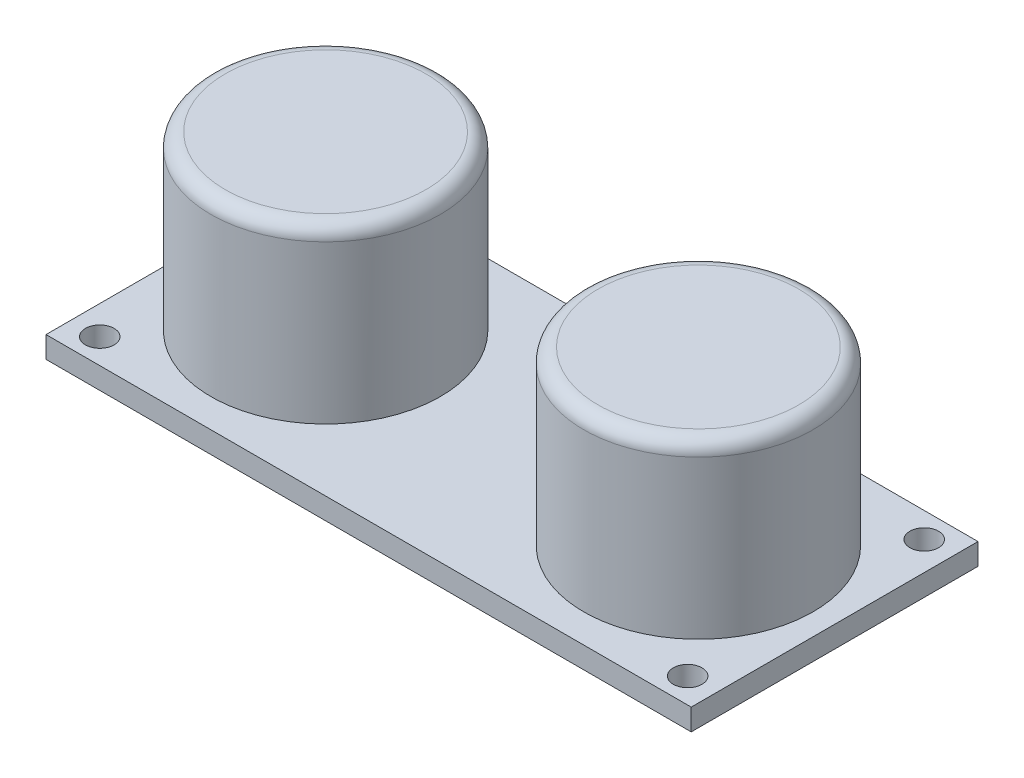
from build123d import *

# Parameters (mm, degrees)
SKETCH1_W           = 45
SKETCH1_H           = 20
SKETCH1_R           = 1
BOSS_EXTRUDE1_DEPTH = 1.5
SKETCH2_R           = 8
BOSS_EXTRUDE2_DEPTH = 12
FILLET1_R           = 1


with BuildPart() as part:
    # Sketch1 → Boss-Extrude1 (new body)
    with BuildSketch(Plane(origin=(0, 0, 0), x_dir=(1, 0, 0), z_dir=(0, 1, 0))):
        with Locations((22.5, 10)):
            Rectangle(SKETCH1_W, SKETCH1_H)
        with Locations((2, 18.25)):
            Circle(SKETCH1_R, mode=Mode.SUBTRACT)
        with Locations((2, 1.75)):
            Circle(SKETCH1_R, mode=Mode.SUBTRACT)
        with Locations((43, 1.75)):
            Circle(SKETCH1_R, mode=Mode.SUBTRACT)
        with Locations((43, 18.25)):
            Circle(SKETCH1_R, mode=Mode.SUBTRACT)
    extrude(amount=BOSS_EXTRUDE1_DEPTH)

    # Sketch2 → Boss-Extrude2 (add)
    with BuildSketch(Plane(origin=(0, 1.5, 0), x_dir=(1, 0, 0), z_dir=(0, 1, 0))):
        with Locations((9.5, 10)):
            Circle(SKETCH2_R)
        with Locations((35.5, 10)):
            Circle(SKETCH2_R)
    extrude(amount=BOSS_EXTRUDE2_DEPTH)

    # Fillet1
    fillet1_edges = [part.edges().sort_by_distance(p)[0] for p in [
        (1.5, 13.5, -10),
        (27.5, 13.5, -10),
    ]]
    fillet(fillet1_edges, radius=FILLET1_R)


solid = part.part
